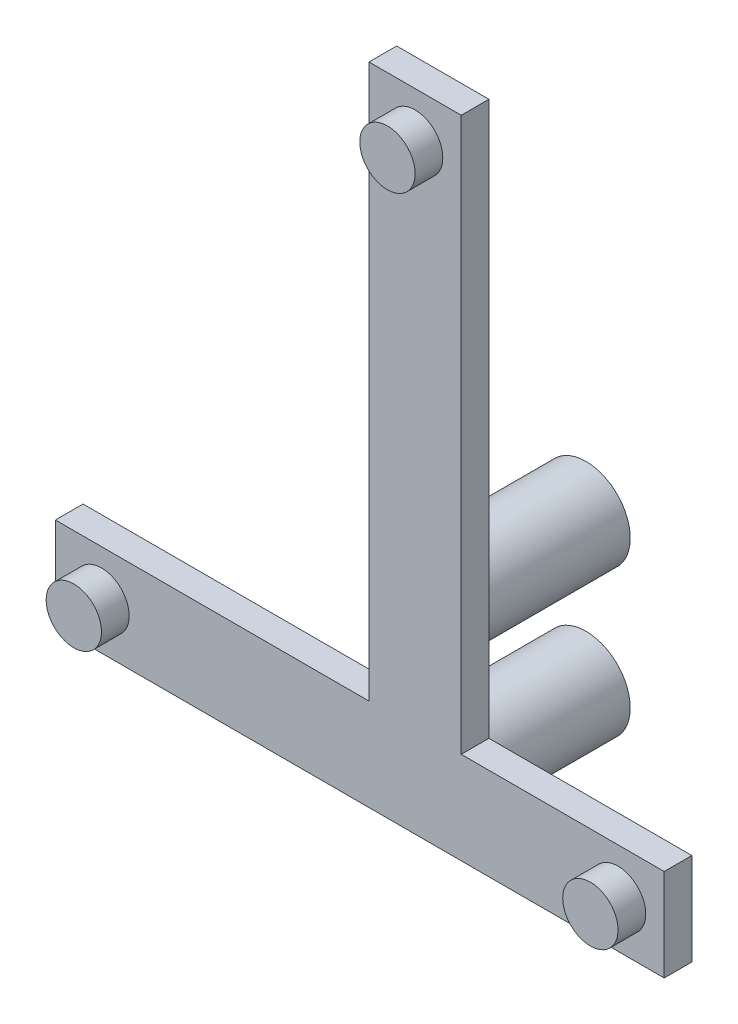
from build123d import *

# Parameters (mm, degrees)
BOSS_EXTRUDE2_DEPTH = 1.5
SKETCH5_R           = 1.5
BOSS_EXTRUDE5_DEPTH = 3
SKETCH6_R           = 2.4
BOSS_EXTRUDE6_DEPTH = 7.76


with BuildPart() as part:
    # Sketch4 → Boss-Extrude2 (new body)
    with BuildSketch(Plane.XY):
        Polygon((-139.561248012, 16.070535031), (-106.561248012, 16.070535031), (-106.561248012, 21.070535031), (-117.561248012, 21.070535031), (-117.561248012, 51.070535031), (-122.561248012, 51.070535031), (-122.561248012, 21.070535031), (-139.561248012, 21.070535031), align=None)
    extrude(amount=BOSS_EXTRUDE2_DEPTH)

    # Sketch5 → Boss-Extrude5 (add)
    with BuildSketch(Plane(origin=(0, 0, 0), x_dir=(-1, 0, 0), z_dir=(0, 0, -1))):
        with Locations((137.061248012, 18.570535031)):
            Circle(SKETCH5_R)
        with Locations((109.061248012, 18.570535031)):
            Circle(SKETCH5_R)
        with Locations((120.061248012, 48.570535031)):
            Circle(SKETCH5_R)
    extrude(amount=-BOSS_EXTRUDE5_DEPTH)

    # Sketch6 → Boss-Extrude6 (add)
    with BuildSketch(Plane(origin=(0, 0, 0), x_dir=(-1, 0, 0), z_dir=(0, 0, -1))):
        with Locations((120.061248012, 18.570535031)):
            Circle(SKETCH6_R)
        with Locations((120.061248012, 26.540535031)):
            Circle(SKETCH6_R)
    extrude(amount=BOSS_EXTRUDE6_DEPTH)


solid = part.part
